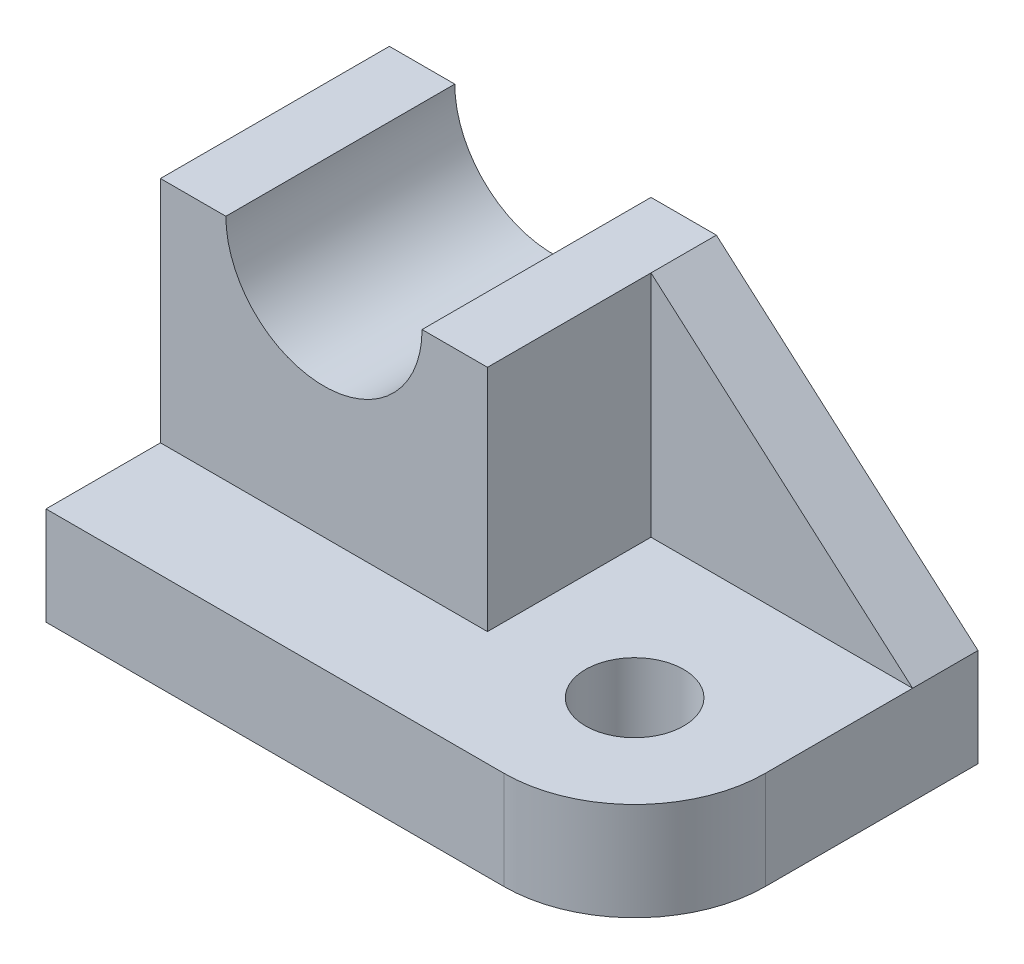
from build123d import *

# Parameters (mm, degrees)
SKETCH1_W           = 72
SKETCH1_H           = 42
BOSS_EXTRUDE1_DEPTH = 12
SKETCH2_W           = 40
SKETCH2_H           = 28
BOSS_EXTRUDE2_DEPTH = 28
SKETCH3_R           = 12
CUT_EXTRUDE1_DEPTH  = 29
BOSS_EXTRUDE3_DEPTH = 8
FILLET3_R           = 16
SKETCH5_R           = 6
CUT_EXTRUDE2_DEPTH  = 13


with BuildPart() as part:
    # Sketch1 → Boss-Extrude1 (new body)
    with BuildSketch(Plane(origin=(0, 0, 0), x_dir=(1, 0, 0), z_dir=(0, 1, 0))):
        Rectangle(SKETCH1_W, SKETCH1_H)
    extrude(amount=BOSS_EXTRUDE1_DEPTH)

    # Sketch2 → Boss-Extrude2 (add)
    with BuildSketch(Plane(origin=(0, 12, 0), x_dir=(1, 0, 0), z_dir=(0, 1, 0))):
        with Locations((-16, 7)):
            Rectangle(SKETCH2_W, SKETCH2_H)
    extrude(amount=BOSS_EXTRUDE2_DEPTH)

    # Sketch3 → Cut-Extrude1 (cut, through all)
    with BuildSketch(Plane.XY.offset(7)):
        with Locations((-16, 40)):
            Circle(SKETCH3_R)
    extrude(amount=-CUT_EXTRUDE1_DEPTH, mode=Mode.SUBTRACT)

    # Sketch4 → Boss-Extrude3 (add)
    with BuildSketch(Plane(origin=(0, 0, -21), x_dir=(-1, 0, 0), z_dir=(0, 0, -1))):
        Polygon((-4, 40), (-4, 12), (-36, 12), align=None)
    extrude(amount=-BOSS_EXTRUDE3_DEPTH)

    # Fillet3
    fillet3_edges = [part.edges().sort_by_distance(p)[0] for p in [
        (36, 6, 21),
    ]]
    fillet(fillet3_edges, radius=FILLET3_R)

    # Sketch5 → Cut-Extrude2 (cut, through all)
    with BuildSketch(Plane(origin=(0, 12, 0), x_dir=(1, 0, 0), z_dir=(0, 1, 0))):
        with Locations((20, -5)):
            Circle(SKETCH5_R)
    extrude(amount=-CUT_EXTRUDE2_DEPTH, mode=Mode.SUBTRACT)


solid = part.part
